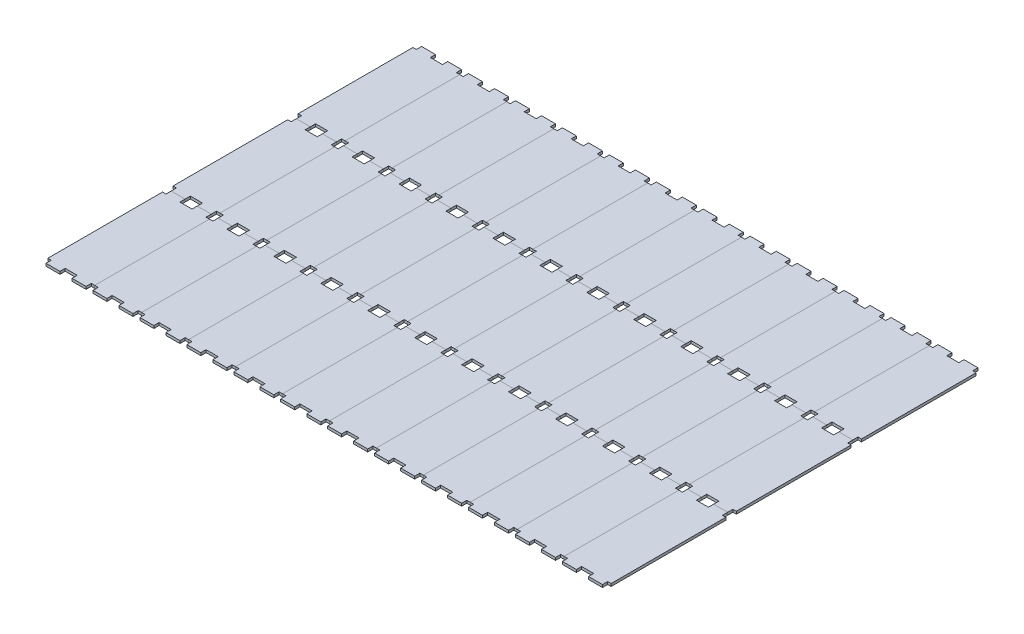
from build123d import *

# Parameters (mm, degrees)
SKETCH1_W           = 57.15
SKETCH1_H           = 152.4
BOSS_EXTRUDE1_DEPTH = 3.175
SKETCH2_W           = 4.195
SKETCH2_H           = 6.35
SKETCH2_W_2         = 7.37
CUT_EXTRUDE1_DEPTH  = 4.175
LPATTERN1_COUNT     = 12
LPATTERN1_PITCH     = 57.15
LPATTERN1_2_COUNT   = 3
LPATTERN1_2_PITCH   = 152.4


with BuildPart() as part:
    # Sketch1 → Boss-Extrude1 (new body)
    with BuildSketch(Plane(origin=(0, 0, 0), x_dir=(1, 0, 0), z_dir=(0, 1, 0))):
        Rectangle(SKETCH1_W, SKETCH1_H)
    extrude(amount=BOSS_EXTRUDE1_DEPTH)

    # Sketch2 → Cut-Extrude1 (cut, through all)
    with BuildSketch(Plane(origin=(0, 3.175, 0), x_dir=(1, 0, 0), z_dir=(0, 1, 0))):
        with Locations((-26.4775, -73.025)):
            Rectangle(SKETCH2_W, SKETCH2_H)
        with Locations((-3.685, -73.025)):
            Rectangle(SKETCH2_W_2, SKETCH2_H)
        with Locations((3.685, -73.025)):
            Rectangle(SKETCH2_W_2, SKETCH2_H)
        with Locations((26.4775, -73.025)):
            Rectangle(SKETCH2_W, SKETCH2_H)
    cut_extrude1 = extrude(amount=-CUT_EXTRUDE1_DEPTH, mode=Mode.SUBTRACT)

    # Mirror1: Cut-Extrude1 across plane
    add(cut_extrude1.mirror(Plane.XY), mode=Mode.SUBTRACT)


with BuildPart() as lpattern1_1:
    # LPattern1: pattern copy
    add(part.part.moved(Location(Vector(1, 0, 0) * (1 * LPATTERN1_PITCH))))


with BuildPart() as lpattern1_2:
    # LPattern1: pattern copy
    add(part.part.moved(Location(Vector(1, 0, 0) * (2 * LPATTERN1_PITCH))))


with BuildPart() as lpattern1_3:
    # LPattern1: pattern copy
    add(part.part.moved(Location(Vector(1, 0, 0) * (3 * LPATTERN1_PITCH))))


with BuildPart() as lpattern1_4:
    # LPattern1: pattern copy
    add(part.part.moved(Location(Vector(1, 0, 0) * (4 * LPATTERN1_PITCH))))


with BuildPart() as lpattern1_5:
    # LPattern1: pattern copy
    add(part.part.moved(Location(Vector(1, 0, 0) * (5 * LPATTERN1_PITCH))))


with BuildPart() as lpattern1_6:
    # LPattern1: pattern copy
    add(part.part.moved(Location(Vector(1, 0, 0) * (6 * LPATTERN1_PITCH))))


with BuildPart() as lpattern1_7:
    # LPattern1: pattern copy
    add(part.part.moved(Location(Vector(1, 0, 0) * (7 * LPATTERN1_PITCH))))


with BuildPart() as lpattern1_8:
    # LPattern1: pattern copy
    add(part.part.moved(Location(Vector(1, 0, 0) * (8 * LPATTERN1_PITCH))))


with BuildPart() as lpattern1_9:
    # LPattern1: pattern copy
    add(part.part.moved(Location(Vector(1, 0, 0) * (9 * LPATTERN1_PITCH))))


with BuildPart() as lpattern1_10:
    # LPattern1: pattern copy
    add(part.part.moved(Location(Vector(1, 0, 0) * (10 * LPATTERN1_PITCH))))


with BuildPart() as lpattern1_11:
    # LPattern1: pattern copy
    add(part.part.moved(Location(Vector(1, 0, 0) * (11 * LPATTERN1_PITCH))))


with BuildPart() as lpattern1_2_1:
    # LPattern1 2: pattern copy
    add(part.part.moved(Location(Vector(0, 0, 1) * (1 * LPATTERN1_2_PITCH))))


with BuildPart() as lpattern1_2_2:
    # LPattern1 2: pattern copy
    add(part.part.moved(Location(Vector(0, 0, 1) * (2 * LPATTERN1_2_PITCH))))


with BuildPart() as lpattern1_2_3:
    # LPattern1 2: pattern copy
    add(lpattern1_1.part.moved(Location(Vector(0, 0, 1) * (1 * LPATTERN1_2_PITCH))))


with BuildPart() as lpattern1_2_4:
    # LPattern1 2: pattern copy
    add(lpattern1_1.part.moved(Location(Vector(0, 0, 1) * (2 * LPATTERN1_2_PITCH))))


with BuildPart() as lpattern1_2_5:
    # LPattern1 2: pattern copy
    add(lpattern1_2.part.moved(Location(Vector(0, 0, 1) * (1 * LPATTERN1_2_PITCH))))


with BuildPart() as lpattern1_2_6:
    # LPattern1 2: pattern copy
    add(lpattern1_2.part.moved(Location(Vector(0, 0, 1) * (2 * LPATTERN1_2_PITCH))))


with BuildPart() as lpattern1_2_7:
    # LPattern1 2: pattern copy
    add(lpattern1_3.part.moved(Location(Vector(0, 0, 1) * (1 * LPATTERN1_2_PITCH))))


with BuildPart() as lpattern1_2_8:
    # LPattern1 2: pattern copy
    add(lpattern1_3.part.moved(Location(Vector(0, 0, 1) * (2 * LPATTERN1_2_PITCH))))


with BuildPart() as lpattern1_2_9:
    # LPattern1 2: pattern copy
    add(lpattern1_4.part.moved(Location(Vector(0, 0, 1) * (1 * LPATTERN1_2_PITCH))))


with BuildPart() as lpattern1_2_10:
    # LPattern1 2: pattern copy
    add(lpattern1_4.part.moved(Location(Vector(0, 0, 1) * (2 * LPATTERN1_2_PITCH))))


with BuildPart() as lpattern1_2_11:
    # LPattern1 2: pattern copy
    add(lpattern1_5.part.moved(Location(Vector(0, 0, 1) * (1 * LPATTERN1_2_PITCH))))


with BuildPart() as lpattern1_2_12:
    # LPattern1 2: pattern copy
    add(lpattern1_5.part.moved(Location(Vector(0, 0, 1) * (2 * LPATTERN1_2_PITCH))))


with BuildPart() as lpattern1_2_13:
    # LPattern1 2: pattern copy
    add(lpattern1_6.part.moved(Location(Vector(0, 0, 1) * (1 * LPATTERN1_2_PITCH))))


with BuildPart() as lpattern1_2_14:
    # LPattern1 2: pattern copy
    add(lpattern1_6.part.moved(Location(Vector(0, 0, 1) * (2 * LPATTERN1_2_PITCH))))


with BuildPart() as lpattern1_2_15:
    # LPattern1 2: pattern copy
    add(lpattern1_7.part.moved(Location(Vector(0, 0, 1) * (1 * LPATTERN1_2_PITCH))))


with BuildPart() as lpattern1_2_16:
    # LPattern1 2: pattern copy
    add(lpattern1_7.part.moved(Location(Vector(0, 0, 1) * (2 * LPATTERN1_2_PITCH))))


with BuildPart() as lpattern1_2_17:
    # LPattern1 2: pattern copy
    add(lpattern1_8.part.moved(Location(Vector(0, 0, 1) * (1 * LPATTERN1_2_PITCH))))


with BuildPart() as lpattern1_2_18:
    # LPattern1 2: pattern copy
    add(lpattern1_8.part.moved(Location(Vector(0, 0, 1) * (2 * LPATTERN1_2_PITCH))))


with BuildPart() as lpattern1_2_19:
    # LPattern1 2: pattern copy
    add(lpattern1_9.part.moved(Location(Vector(0, 0, 1) * (1 * LPATTERN1_2_PITCH))))


with BuildPart() as lpattern1_2_20:
    # LPattern1 2: pattern copy
    add(lpattern1_9.part.moved(Location(Vector(0, 0, 1) * (2 * LPATTERN1_2_PITCH))))


with BuildPart() as lpattern1_2_21:
    # LPattern1 2: pattern copy
    add(lpattern1_10.part.moved(Location(Vector(0, 0, 1) * (1 * LPATTERN1_2_PITCH))))


with BuildPart() as lpattern1_2_22:
    # LPattern1 2: pattern copy
    add(lpattern1_10.part.moved(Location(Vector(0, 0, 1) * (2 * LPATTERN1_2_PITCH))))


with BuildPart() as lpattern1_2_23:
    # LPattern1 2: pattern copy
    add(lpattern1_11.part.moved(Location(Vector(0, 0, 1) * (1 * LPATTERN1_2_PITCH))))


with BuildPart() as lpattern1_2_24:
    # LPattern1 2: pattern copy
    add(lpattern1_11.part.moved(Location(Vector(0, 0, 1) * (2 * LPATTERN1_2_PITCH))))


solid = Compound([part.part, lpattern1_1.part, lpattern1_2.part, lpattern1_3.part, lpattern1_4.part, lpattern1_5.part, lpattern1_6.part, lpattern1_7.part, lpattern1_8.part, lpattern1_9.part, lpattern1_10.part, lpattern1_11.part, lpattern1_2_1.part, lpattern1_2_2.part, lpattern1_2_3.part, lpattern1_2_4.part, lpattern1_2_5.part, lpattern1_2_6.part, lpattern1_2_7.part, lpattern1_2_8.part, lpattern1_2_9.part, lpattern1_2_10.part, lpattern1_2_11.part, lpattern1_2_12.part, lpattern1_2_13.part, lpattern1_2_14.part, lpattern1_2_15.part, lpattern1_2_16.part, lpattern1_2_17.part, lpattern1_2_18.part, lpattern1_2_19.part, lpattern1_2_20.part, lpattern1_2_21.part, lpattern1_2_22.part, lpattern1_2_23.part, lpattern1_2_24.part])
